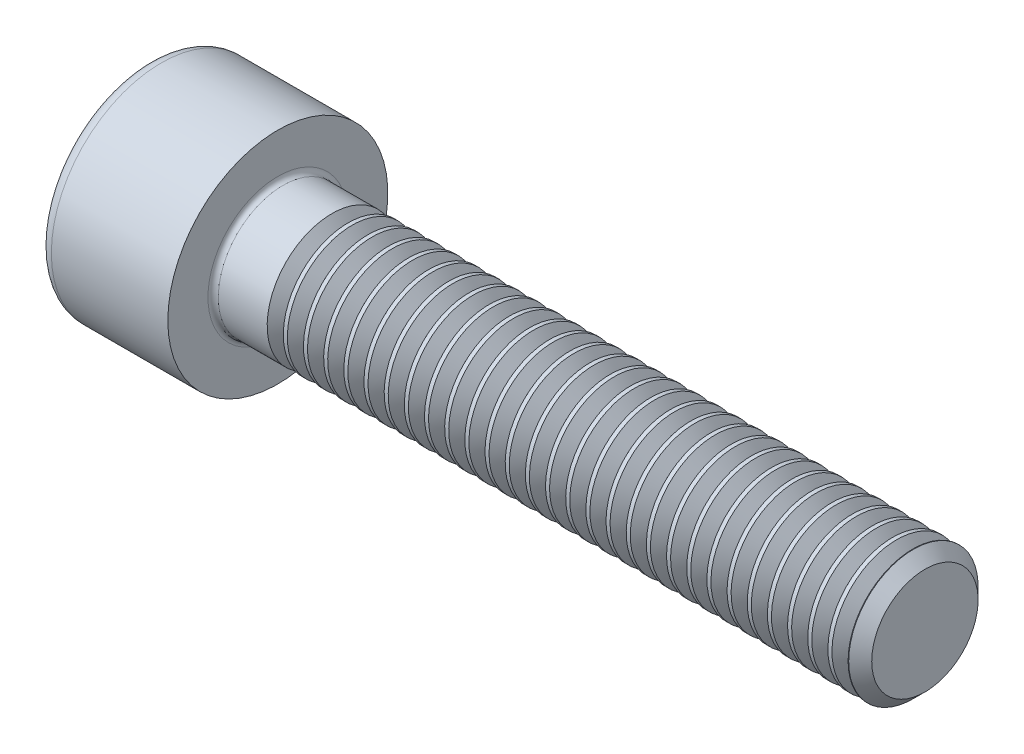
from build123d import *

# Parameters (mm, degrees)
FILLET1_R       = 0.2
FILLET2_R       = 0.5
HEX_2_DEPTH     = 2.5
THDSCHPAT_COUNT = 29
THDSCHPAT_PITCH = 0.779310345


with BuildPart() as part:
    # BodySke → Base-Revolve (revolve)
    with BuildSketch(Plane.XY):
        Polygon((0, 0), (0, 4.25), (5, 4.25), (5, 2.5), (29.555, 2.5), (30, 2.055), (30, 0), align=None)
    revolve(axis=Axis((-31.75, 0, 0), (1, 0, 0)))

    # Fillet1
    fillet1_edges = [part.edges().sort_by_distance(p)[0] for p in [
        (5, -2.5, 0),
    ]]
    fillet(fillet1_edges, radius=FILLET1_R)

    # Fillet2
    fillet2_edges = [part.edges().sort_by_distance(p)[0] for p in [
        (0, -4.25, 0),
    ]]
    fillet(fillet2_edges, radius=FILLET2_R)

    # Sketch2 → Hex-PreBroach (revolve, cut)
    with BuildSketch(Plane.XY):
        Polygon((0, 2.01), (2.5, 2.01), (3.660474041, 0), (0, 0), align=None)
    revolve(axis=Axis((0, 0, 0), (1, 0, 0)), mode=Mode.SUBTRACT)

    # Sketch3 → Hex 2 (cut)
    with BuildSketch(Plane(origin=(0, 0, 0), x_dir=(0, 0.5, 0.866025404), z_dir=(-1, 0, 0))):
        Polygon((1.160474041, 2.01), (-1.160474041, 2.01), (-2.320948082, 0), (-1.160474041, -2.01), (1.160474041, -2.01), (2.320948082, 0), align=None)
    extrude(amount=-HEX_2_DEPTH, mode=Mode.SUBTRACT)

    # ThdSchSke → ThreadSchematic (revolve, cut)
    with BuildSketch(Plane.XY):
        Polygon((7.4, -2.055), (7.088407645, -2.5), (7.088407645, -3.125), (7.711592355, -3.125), (7.711592355, -2.5), align=None)
    threadschematic = revolve(axis=Axis((-3.175, 0, 0), (1, 0, 0)), mode=Mode.SUBTRACT)

    # ThdSchPat: ThreadSchematic ×29
    with Locations(*[(i * THDSCHPAT_PITCH, 0, 0) for i in range(1, THDSCHPAT_COUNT)]):
        add(threadschematic, mode=Mode.SUBTRACT)


solid = part.part
